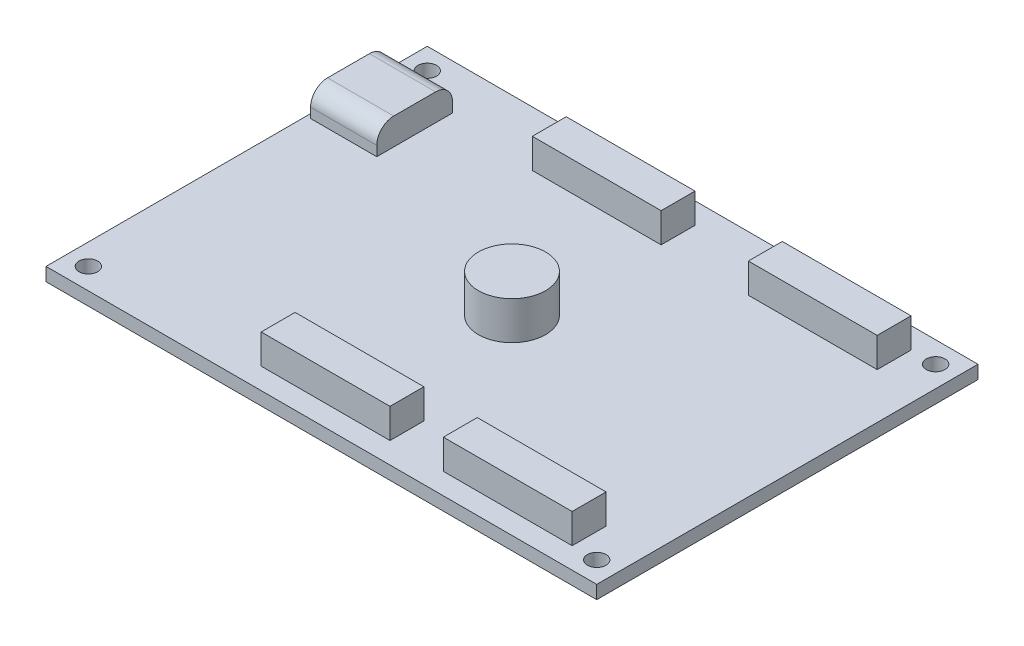
from build123d import *

# Parameters (mm, degrees)
SKETCH1_W                = 65
SKETCH1_H                = 45
SKETCH1_R                = 1.1
BOSS_EXTRUDE1_DEPTH      = 1.57
SKETCH1_4_W              = 15.2
SKETCH1_4_H              = 4
BOSS_EXTRUDE2_DEPTH      = 3.5
BOSS_EXTRUDE3_DEPTH      = 4.5
BOSS_EXTRUDE3_DEPTH_BACK = 3.97
SKETCH1_5_R              = 3.9620477
SKETCH2_W                = 7.81
SKETCH2_H                = 8.94
BOSS_EXTRUDE4_DEPTH      = 3.16
FILLET1_R                = 2


with BuildPart() as part:
    # Sketch1 → Boss-Extrude1 (new body)
    with BuildSketch(Plane(origin=(0, 0, 0), x_dir=(1, 0, 0), z_dir=(0, 1, 0))):
        Rectangle(SKETCH1_W, SKETCH1_H)
        with Locations((-30, -20)):
            Circle(SKETCH1_R, mode=Mode.SUBTRACT)
        with Locations((30, -20)):
            Circle(SKETCH1_R, mode=Mode.SUBTRACT)
        with Locations((-30, 20)):
            Circle(SKETCH1_R, mode=Mode.SUBTRACT)
        with Locations((30, 20)):
            Circle(SKETCH1_R, mode=Mode.SUBTRACT)
    extrude(amount=-BOSS_EXTRUDE1_DEPTH)

    # Sketch1_4 → Boss-Extrude2 (add)
    with BuildSketch(Plane(origin=(0, 0, 0), x_dir=(1, 0, 0), z_dir=(0, 1, 0))):
        with Locations((-2, -18)):
            Rectangle(SKETCH1_4_W, SKETCH1_4_H)
        with Locations((19.5, -18)):
            Rectangle(SKETCH1_4_W, SKETCH1_4_H)
        with Locations((-6, 18)):
            Rectangle(SKETCH1_4_W, SKETCH1_4_H)
        with Locations((19.5, 18)):
            Rectangle(SKETCH1_4_W, SKETCH1_4_H)
    extrude(amount=BOSS_EXTRUDE2_DEPTH)

    # Sketch1_5 → Boss-Extrude3 (add, two sides: drawn at the far end of the back side and taken through both)
    with BuildSketch(Plane(origin=(0, 0, 0), x_dir=(1, 0, 0), z_dir=(0, 1, 0)).offset(-BOSS_EXTRUDE3_DEPTH_BACK)):
        Circle(SKETCH1_5_R)
    extrude(amount=BOSS_EXTRUDE3_DEPTH + BOSS_EXTRUDE3_DEPTH_BACK)

    # Sketch2 → Boss-Extrude4 (add)
    with BuildSketch(Plane(origin=(0, 0, 0), x_dir=(1, 0, 0), z_dir=(0, 1, 0))):
        with Locations((-28.095, 12.70000129)):
            Rectangle(SKETCH2_W, SKETCH2_H)
    extrude(amount=BOSS_EXTRUDE4_DEPTH)

    # Fillet1
    fillet1_edges = [part.edges().sort_by_distance(p)[0] for p in [
        (-28.095, 3.16, -17.17000129),
        (-28.095, 3.16, -8.23000129),
    ]]
    fillet(fillet1_edges, radius=FILLET1_R)


solid = part.part
